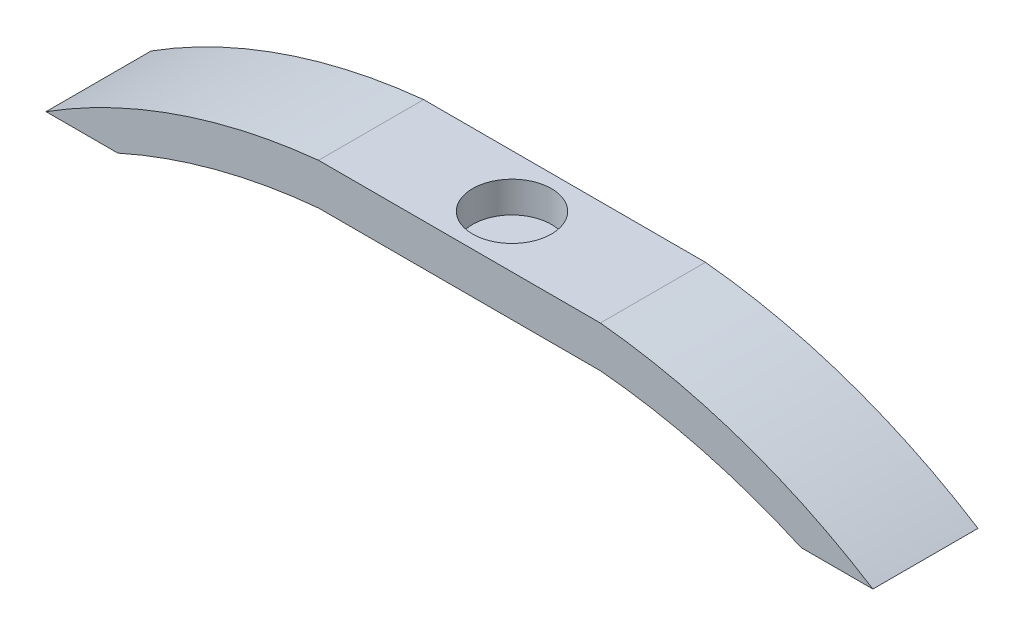
from build123d import *

# Parameters (mm, degrees)
SKETCH1_W           = 15.24
SKETCH1_H           = 10.16
BOSS_EXTRUDE1_DEPTH = 4
BOSS_EXTRUDE2_DEPTH = 10.16
SKETCH3_R           = 3.81
CUT_EXTRUDE1_DEPTH  = 3


with BuildPart() as part:
    # Sketch1 → Boss-Extrude1 (new body)
    with BuildSketch(Plane(origin=(0, 0, 0), x_dir=(1, 0, 0), z_dir=(0, 1, 0))):
        Rectangle(SKETCH1_W, SKETCH1_H)
    extrude(amount=BOSS_EXTRUDE1_DEPTH)

    # Sketch2 → Boss-Extrude2 (add)
    with BuildSketch(Plane.XY.offset(5.08)):
        with BuildLine():
            Line((13.62, 4), (7.62, 4))
            Line((7.62, 4), (7.62, 0))
            Line((7.62, 0), (13.62, 0))
            ThreePointArc((13.62, 0), (23.535142279, -1.740916975), (33.025, -5.1))
            Line((33.025, -5.1), (39.965, -5.1))
            ThreePointArc((39.965, -5.1), (27.323058228, 0.985995221), (13.62, 4))
        make_face()
        with BuildLine():
            Line((-7.62, 0), (-7.62, 4))
            Line((-7.62, 4), (-13.62, 4))
            ThreePointArc((-13.62, 4), (-27.323058228, 0.985995221), (-39.965, -5.1))
            Line((-39.965, -5.1), (-33.025, -5.1))
            ThreePointArc((-33.025, -5.1), (-23.535142279, -1.740916975), (-13.62, 0))
            Line((-13.62, 0), (-7.62, 0))
        make_face()
    extrude(amount=-BOSS_EXTRUDE2_DEPTH)

    # Sketch3 → Cut-Extrude1 (cut)
    with BuildSketch(Plane(origin=(0, 4, 0), x_dir=(1, 0, 0), z_dir=(0, 1, 0))):
        Circle(SKETCH3_R)
    extrude(amount=-CUT_EXTRUDE1_DEPTH, mode=Mode.SUBTRACT)


solid = part.part
